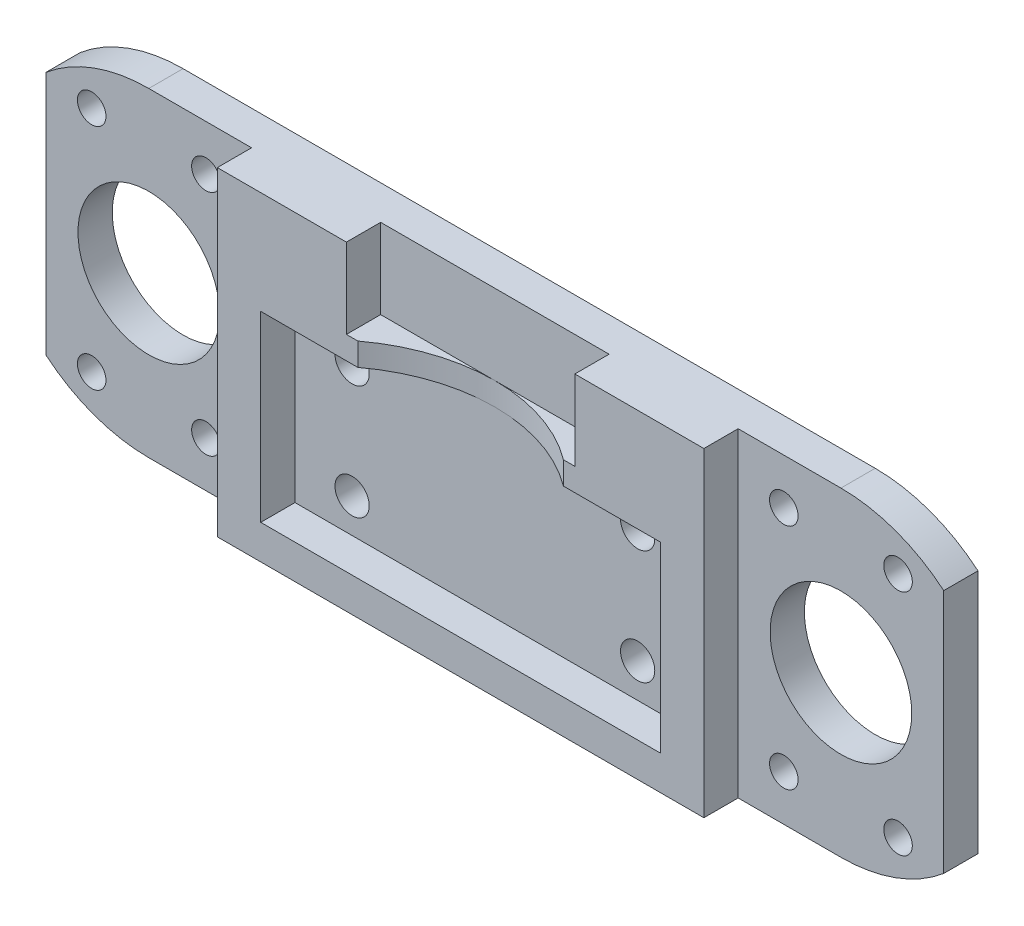
from build123d import *

# Parameters (mm, degrees)
SKETCH1_R              = 6.2
SKETCH1_R_2            = 1.25
MAIN_DEPTH             = 1.5
SKETCH2_W              = 35
SKETCH2_H              = 16
FRAMEWORK_DEPTH        = 3
SKETCH3_R              = 1.5
FIXHOLE_DEPTH          = 7
HOLEPATTERN_COUNT      = 2
HOLEPATTERN_PITCH      = 25
HOLEPATTERN_COUNT_DIR2 = 2
HOLEPATTERN_PITCH_DIR2 = 10
CUT_EXTRUDE1_REACH     = 23
SKETCH4_R              = 15


with BuildPart() as part:
    # Sketch1 → Main (new body, symmetric)
    with BuildSketch(Plane.XY):
        with BuildLine():
            Line((-39.3, 10.723805295), (-39.3, -10.723805295))
            ThreePointArc((-39.3, -10.723805295), (-35.08887909, -13.155479355), (-30.3, -14))
            Line((-30.3, -14), (30.3, -14))
            ThreePointArc((30.3, -14), (35.08887909, -13.155479355), (39.3, -10.723805295))
            Line((39.3, -10.723805295), (39.3, 10.723805295))
            ThreePointArc((39.3, 10.723805295), (35.08887909, 13.155479355), (30.3, 14))
            Line((30.3, 14), (-30.3, 14))
            ThreePointArc((-30.3, 14), (-35.08887909, 13.155479355), (-39.3, 10.723805295))
        make_face()
        with Locations((-30.3, 0)):
            Circle(SKETCH1_R, mode=Mode.SUBTRACT)
        with Locations((-35.3, 10)):
            Circle(SKETCH1_R_2, mode=Mode.SUBTRACT)
        with Locations((-25.3, 10)):
            Circle(SKETCH1_R_2, mode=Mode.SUBTRACT)
        with Locations((-35.3, -10)):
            Circle(SKETCH1_R_2, mode=Mode.SUBTRACT)
        with Locations((-25.3, -10)):
            Circle(SKETCH1_R_2, mode=Mode.SUBTRACT)
        with Locations((30.3, 0)):
            Circle(SKETCH1_R, mode=Mode.SUBTRACT)
        with Locations((25.3, 10)):
            Circle(SKETCH1_R_2, mode=Mode.SUBTRACT)
        with Locations((35.3, 10)):
            Circle(SKETCH1_R_2, mode=Mode.SUBTRACT)
        with Locations((25.3, -10)):
            Circle(SKETCH1_R_2, mode=Mode.SUBTRACT)
        with Locations((35.3, -10)):
            Circle(SKETCH1_R_2, mode=Mode.SUBTRACT)
    extrude(amount=MAIN_DEPTH, both=True)

    # Sketch2 → Framework (add)
    with BuildSketch(Plane(origin=(0, 0, 1.5), x_dir=(-1, 0, 0), z_dir=(0, 0, -1))):
        Polygon((21.3, 14), (10, 14), (10, 7), (-10, 7), (-10, 14), (-21.3, 14), (-21.3, -14), (21.3, -14), align=None)
        with Locations((0, -3)):
            Rectangle(SKETCH2_W, SKETCH2_H, mode=Mode.SUBTRACT)
    extrude(amount=-FRAMEWORK_DEPTH)

    # Sketch3 → FixHole (cut, through all)
    with BuildSketch(Plane(origin=(0, 0, -1.5), x_dir=(-1, 0, 0), z_dir=(0, 0, -1))):
        with Locations((12.5, -8)):
            Circle(SKETCH3_R)
    fixhole = extrude(amount=-FIXHOLE_DEPTH, mode=Mode.SUBTRACT)

    # HolePattern: FixHole 2 × 2
    with Locations(*[(i * HOLEPATTERN_PITCH, j * HOLEPATTERN_PITCH_DIR2, 0) for i in range(HOLEPATTERN_COUNT) for j in range(HOLEPATTERN_COUNT_DIR2) if (i, j) != (0, 0)]):
        add(fixhole, mode=Mode.SUBTRACT)

    # Sketch4 → Cut-Extrude1 (cut, up to next)
    with BuildSketch(Plane(origin=(0, 7, 0), x_dir=(1, 0, 0), z_dir=(0, 1, 0)), mode=Mode.PRIVATE) as cut_extrude1_sk1:
        with Locations((0, -16.5)):
            Circle(SKETCH4_R)
    cut_extrude1_tool1 = extrude(cut_extrude1_sk1.sketch, amount=-CUT_EXTRUDE1_REACH, mode=Mode.PRIVATE) & part.part
    add(cut_extrude1_tool1.solids().sort_by_distance((0, 7, 16.5))[0], mode=Mode.SUBTRACT)


solid = part.part
